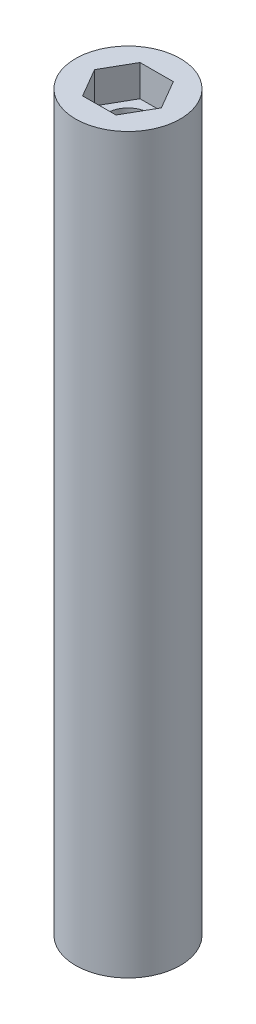
from build123d import *

# Parameters (mm, degrees)
SKETCH1_R           = 5
BOSS_EXTRUDE1_DEPTH = 70
SKETCH2_R           = 2
CUT_EXTRUDE1_DEPTH  = 71
CUT_EXTRUDE2_DEPTH  = 3
LPATTERN1_COUNT     = 2
LPATTERN1_PITCH     = 67


with BuildPart() as part:
    # Sketch1 → Boss-Extrude1 (new body)
    with BuildSketch(Plane(origin=(0, 0, 0), x_dir=(1, 0, 0), z_dir=(0, 1, 0))):
        Circle(SKETCH1_R)
    extrude(amount=BOSS_EXTRUDE1_DEPTH)

    # Sketch2 → Cut-Extrude1 (cut, through all)
    with BuildSketch(Plane(origin=(0, 70, 0), x_dir=(1, 0, 0), z_dir=(0, 1, 0))):
        Circle(SKETCH2_R)
    extrude(amount=-CUT_EXTRUDE1_DEPTH, mode=Mode.SUBTRACT)

    # Sketch3 → Cut-Extrude2 (cut)
    with BuildSketch(Plane(origin=(0, 70, 0), x_dir=(1, 0, 0), z_dir=(0, 1, 0))):
        Polygon((1.599030575, -2.74343481), (3.175399526, 0.013083694), (1.576368951, 2.756518504), (-1.599030575, 2.74343481), (-3.175399526, -0.013083694), (-1.576368951, -2.756518504), align=None)
    cut_extrude2 = extrude(amount=-CUT_EXTRUDE2_DEPTH, mode=Mode.SUBTRACT)

    # LPattern1: Cut-Extrude2 ×2
    with Locations(*[(0, -i * LPATTERN1_PITCH, 0) for i in range(1, LPATTERN1_COUNT)]):
        add(cut_extrude2, mode=Mode.SUBTRACT)


solid = part.part
